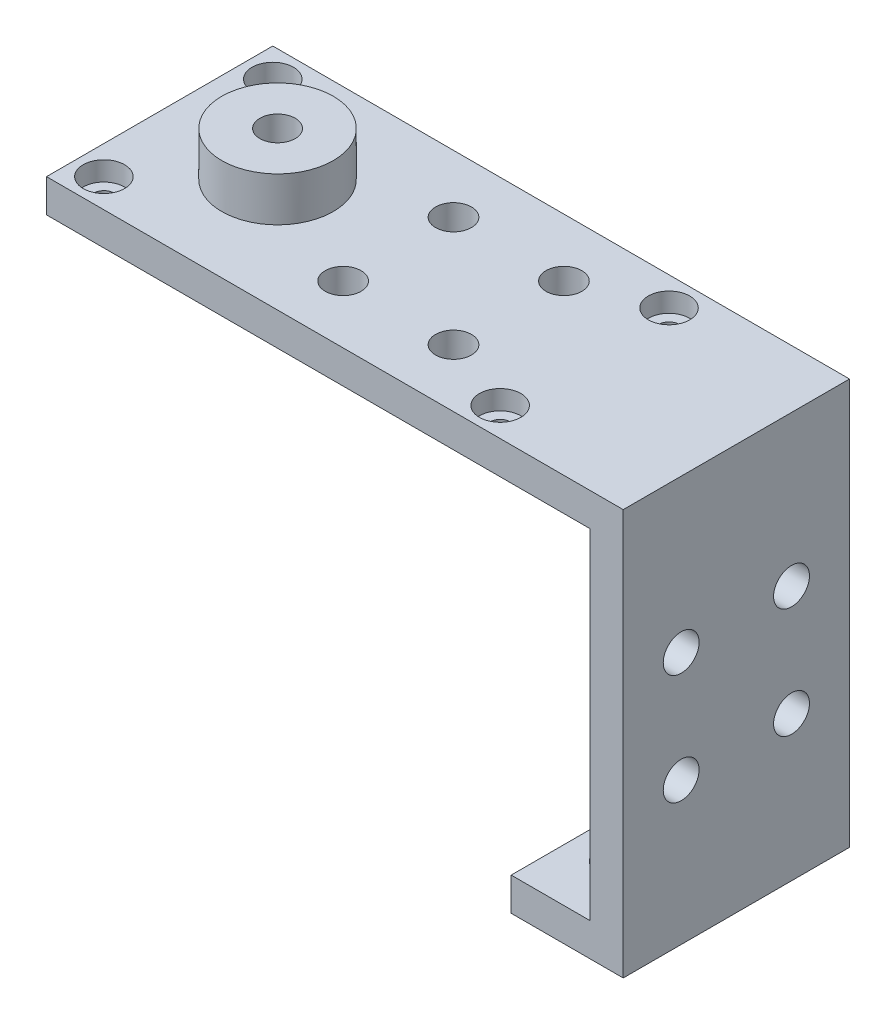
from build123d import *

# Parameters (mm, degrees)
SKETCH1_W           = 52.25
SKETCH1_H           = 20.5
BOSS_EXTRUDE1_DEPTH = 3
SKETCH2_W           = 3
SKETCH2_H           = 20.5
BOSS_EXTRUDE2_DEPTH = 33.75
SKETCH3_W           = 20.5
SKETCH3_H           = 3
BOSS_EXTRUDE3_DEPTH = 7.15
SKETCH4_R           = 1.625
CUT_EXTRUDE1_DEPTH  = 3
SKETCH5_W           = 1.8
SKETCH5_H           = 1.3
CUT_EXTRUDE2_DEPTH  = 7.15
SKETCH6_R           = 1.625
CUT_EXTRUDE3_DEPTH  = 3
SKETCH7_R           = 1.625
CUT_EXTRUDE4_DEPTH  = 3
SKETCH8_R           = 1.875
CUT_EXTRUDE5_DEPTH  = 1.75
SKETCH9_R           = 0.925
CUT_EXTRUDE6_DEPTH  = 1.25
SKETCH12_R          = 5.05
BOSS_EXTRUDE4_DEPTH = 4
SKETCH11_R          = 4
CUT_EXTRUDE7_DEPTH  = 3
SKETCH13_R          = 1.6
CUT_EXTRUDE8_DEPTH  = 4


with BuildPart() as part:
    # Sketch1 → Boss-Extrude1 (new body)
    with BuildSketch(Plane(origin=(0, 0, 0), x_dir=(1, 0, 0), z_dir=(0, 1, 0))):
        Rectangle(SKETCH1_W, SKETCH1_H)
    extrude(amount=-BOSS_EXTRUDE1_DEPTH)

    # Sketch2 → Boss-Extrude2 (add)
    with BuildSketch(Plane.XZ.offset(3)):
        with Locations((24.625, 0)):
            Rectangle(SKETCH2_W, SKETCH2_H)
    extrude(amount=BOSS_EXTRUDE2_DEPTH)

    # Sketch3 → Boss-Extrude3 (add)
    with BuildSketch(Plane.ZY.offset(-23.125)):
        with Locations((0, -35.25)):
            Rectangle(SKETCH3_W, SKETCH3_H)
    extrude(amount=BOSS_EXTRUDE3_DEPTH)

    # Sketch4 → Cut-Extrude1 (cut)
    with BuildSketch(Plane.XZ.offset(36.75)):
        with Locations((19.575, 4.475)):
            Circle(SKETCH4_R)
        with Locations((19.575, -4.475)):
            Circle(SKETCH4_R)
    extrude(amount=-CUT_EXTRUDE1_DEPTH, mode=Mode.SUBTRACT)

    # Sketch5 → Cut-Extrude2 (cut)
    with BuildSketch(Plane.ZY.offset(-15.975)):
        with Locations((0.235327499, -34.4)):
            Rectangle(SKETCH5_W, SKETCH5_H)
    extrude(amount=-CUT_EXTRUDE2_DEPTH, mode=Mode.SUBTRACT)

    # Sketch6 → Cut-Extrude3 (cut)
    with BuildSketch(Plane.ZY.offset(-23.125)):
        with Locations((-4.997772224, -13.625)):
            Circle(SKETCH6_R)
        with Locations((-4.997772224, -23.625)):
            Circle(SKETCH6_R)
        with Locations((5, -23.836070013)):
            Circle(SKETCH6_R)
        with Locations((5, -13.836070013)):
            Circle(SKETCH6_R)
    extrude(amount=-CUT_EXTRUDE3_DEPTH, mode=Mode.SUBTRACT)

    # Sketch7 → Cut-Extrude4 (cut)
    with BuildSketch(Plane(origin=(0, 0, 0), x_dir=(1, 0, 0), z_dir=(0, 1, 0))):
        with Locations((-4.5, 5)):
            Circle(SKETCH7_R)
        with Locations((-4.5, -5)):
            Circle(SKETCH7_R)
        with Locations((5.5, 5)):
            Circle(SKETCH7_R)
        with Locations((5.5, -5)):
            Circle(SKETCH7_R)
    extrude(amount=-CUT_EXTRUDE4_DEPTH, mode=Mode.SUBTRACT)

    # Sketch8 → Cut-Extrude5 (cut)
    with BuildSketch(Plane(origin=(0, 0, 0), x_dir=(1, 0, 0), z_dir=(0, 1, 0))):
        with Locations((-23.525, 7.65)):
            Circle(SKETCH8_R)
        with Locations((-23.525, -7.65)):
            Circle(SKETCH8_R)
        with Locations((12.375, 7.65)):
            Circle(SKETCH8_R)
        with Locations((12.375, -7.65)):
            Circle(SKETCH8_R)
    extrude(amount=-CUT_EXTRUDE5_DEPTH, mode=Mode.SUBTRACT)

    # Sketch9 → Cut-Extrude6 (cut)
    with BuildSketch(Plane(origin=(0, -1.75, 0), x_dir=(1, 0, 0), z_dir=(0, 1, 0))):
        with Locations((-23.525, 7.65)):
            Circle(SKETCH9_R)
        with Locations((-23.525, -7.65)):
            Circle(SKETCH9_R)
        with Locations((12.375, -7.65)):
            Circle(SKETCH9_R)
        with Locations((12.375, 7.65)):
            Circle(SKETCH9_R)
    extrude(amount=-CUT_EXTRUDE6_DEPTH, mode=Mode.SUBTRACT)

    # Sketch12 → Boss-Extrude4 (add)
    with BuildSketch(Plane(origin=(0, 0, 0), x_dir=(1, 0, 0), z_dir=(0, 1, 0))):
        with Locations((-15.442849896, 0)):
            Circle(SKETCH12_R)
    extrude(amount=BOSS_EXTRUDE4_DEPTH)

    # Sketch11 → Cut-Extrude7 (cut)
    with BuildSketch(Plane.XZ.offset(3)):
        with Locations((-15.442849896, 0)):
            Circle(SKETCH11_R)
    extrude(amount=-CUT_EXTRUDE7_DEPTH, mode=Mode.SUBTRACT)

    # Sketch13 → Cut-Extrude8 (cut)
    with BuildSketch(Plane.XZ):
        with Locations((-15.442849896, 0)):
            Circle(SKETCH13_R)
    extrude(amount=-CUT_EXTRUDE8_DEPTH, mode=Mode.SUBTRACT)


solid = part.part
